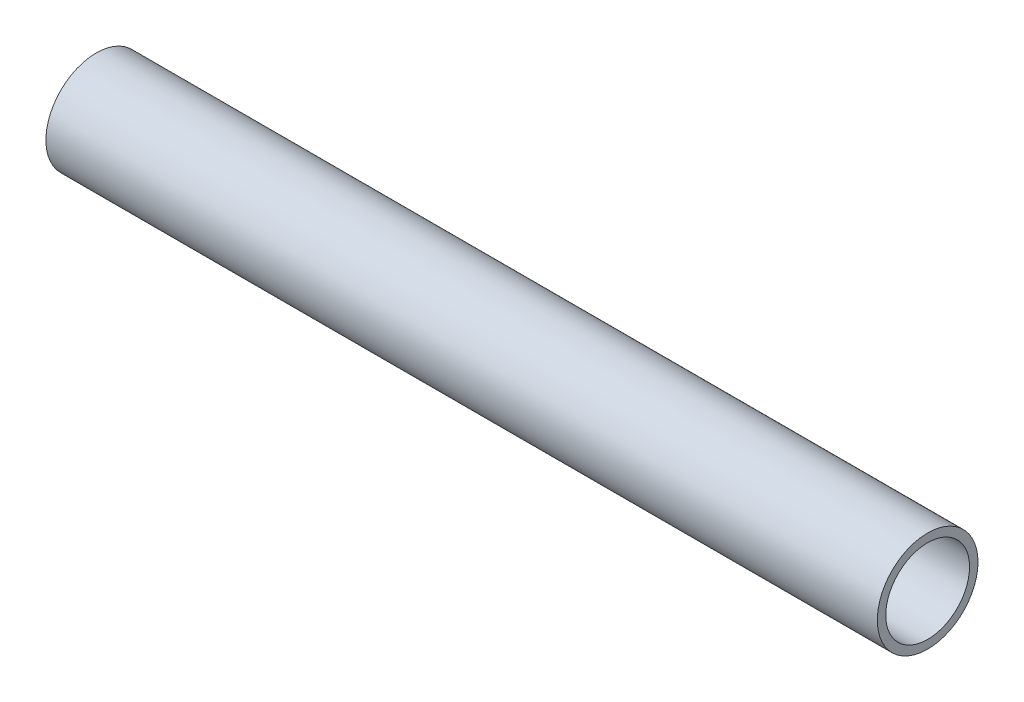
from build123d import *

# Parameters (mm, degrees)
SKETCH11_R              = 6.35
SKETCH11_R_2            = 5.2832
PIPE_0_5_SCH_40_1_DEPTH = 104.845519507


with BuildPart() as part:
    # Sketch11 → Pipe 0.5 SCH 40(1) (new body)
    with BuildSketch(Plane(origin=(-143.613946583, 1471.859674504, 0), x_dir=(0, 1, 0), z_dir=(1, 0, 0))):
        Circle(SKETCH11_R)
        Circle(SKETCH11_R_2, mode=Mode.SUBTRACT)
    extrude(amount=PIPE_0_5_SCH_40_1_DEPTH)


solid = part.part
